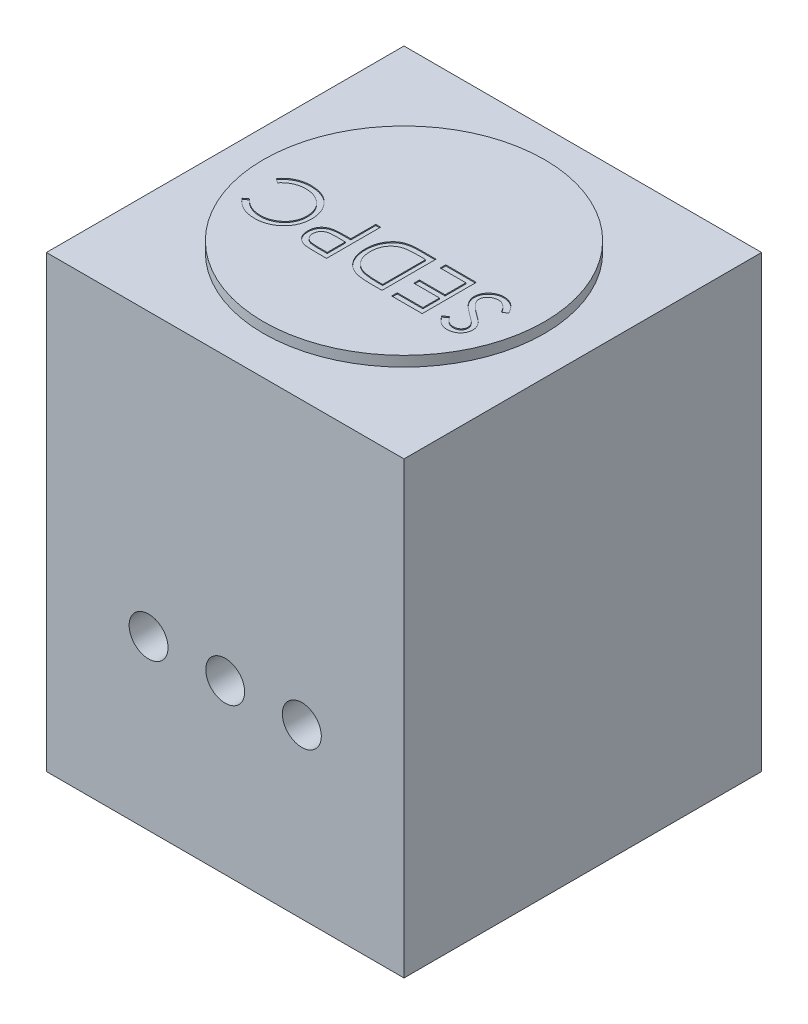
from build123d import *

# Parameters (mm, degrees)
CROQUIS1_W              = 700
CROQUIS1_H              = 700
SALIENTE_EXTRUIR1_DEPTH = 900
CROQUIS2_W              = 700
CROQUIS2_H              = 700
CROQUIS2_R              = 275
CORTAR_EXTRUIR1_DEPTH   = 20
CORTAR_EXTRUIR2_DEPTH   = 2
CROQUIS4_R              = 38.1
CORTAR_EXTRUIR3_DEPTH   = 94


with BuildPart() as part:
    # Croquis1 → Saliente-Extruir1 (new body)
    with BuildSketch(Plane(origin=(0, 0, 0), x_dir=(1, 0, 0), z_dir=(0, 1, 0))):
        Rectangle(CROQUIS1_W, CROQUIS1_H)
    extrude(amount=SALIENTE_EXTRUIR1_DEPTH)

    # Croquis2 → Cortar-Extruir1 (cut)
    with BuildSketch(Plane(origin=(0, 900, 0), x_dir=(1, 0, 0), z_dir=(0, 1, 0))):
        Rectangle(CROQUIS2_W, CROQUIS2_H)
        Circle(CROQUIS2_R, mode=Mode.SUBTRACT)
    extrude(amount=-CORTAR_EXTRUIR1_DEPTH, mode=Mode.SUBTRACT)

    # Croquis3 → Cortar-Extruir2 (cut)
    with BuildSketch(Plane(origin=(0, 900, 0), x_dir=(1, 0, 0), z_dir=(0, 1, 0))):
        with BuildLine():
            Line((225.596474991, -20.416165865), (216.649827021, -25.77991453))
            add(Edge.make_bspline(
                [(216.649827021, -25.77991453), (215.817727942, -24.387015271), (214.223458218, -21.718274043), (211.563976644, -18.112138059), (208.808290997, -15.047139509), (205.935994482, -12.541108757), (202.964619384, -10.568106706), (199.874768236, -9.171039223), (196.676853483, -8.299699015), (194.500502215, -8.193863064), (193.413983004, -8.141025641)],
                knots=[0, 0, 0, 0, 0.004865339, 0.009321801, 0.013419003, 0.01720638, 0.020728614, 0.024078105, 0.027343409, 0.030598786, 0.030598786, 0.030598786, 0.030598786], degree=3))
            add(Edge.make_bspline(
                [(193.413983004, -8.141025641), (192.486258551, -8.16748411), (190.647042645, -8.219938088), (187.934115432, -8.703590884), (185.312497191, -9.494843293), (182.808280262, -10.567480732), (180.487694037, -11.885952935), (178.420448395, -13.440792446), (176.673769299, -15.236952433), (175.229739432, -17.209670794), (174.099328955, -19.317768818), (173.295014972, -21.509329726), (172.7783411, -23.770388295), (172.712834257, -25.3036922), (172.679808324, -26.076722756)],
                knots=[0, 0, 0, 0, 0.002781239, 0.005513813, 0.008236913, 0.010981714, 0.013669176, 0.016226023, 0.018714722, 0.02115721, 0.023537915, 0.025865446, 0.028144287, 0.030461367, 0.030461367, 0.030461367, 0.030461367], degree=3))
            add(Edge.make_bspline(
                [(172.679808324, -26.076722756), (172.723431182, -26.958180652), (172.811772226, -28.743229007), (173.590327709, -31.381364234), (174.779149349, -34.003377867), (175.896508086, -35.625567699), (176.474713506, -36.465010684)],
                knots=[0, 0, 0, 0, 0.002639196, 0.005344661, 0.008190598, 0.011242672, 0.011242672, 0.011242672, 0.011242672], degree=3))
            add(Edge.make_bspline(
                [(176.474713506, -36.465010684), (176.947151926, -37.072504438), (177.941888667, -38.351605232), (179.677170342, -40.222155324), (181.650294936, -42.202722647), (183.912347365, -44.253775405), (186.430342054, -46.41726949), (189.232825966, -48.653080301), (192.287075739, -50.994554054), (194.44132706, -52.54103014), (195.555242352, -53.340678419)],
                knots=[0, 0, 0, 0, 0.00230775, 0.004859054, 0.007647394, 0.010693573, 0.014016389, 0.017605492, 0.021447189, 0.025560594, 0.025560594, 0.025560594, 0.025560594], degree=3))
            add(Edge.make_bspline(
                [(195.555242352, -53.340678419), (196.668581328, -54.13396248), (198.79720067, -55.650661197), (201.77632083, -57.898762949), (204.436738297, -59.967264951), (206.792009221, -61.827353734), (208.78119976, -63.560156947), (210.47702916, -65.072806021), (211.816931859, -66.446074693), (212.562556107, -67.336222832), (212.897323014, -67.735877404)],
                knots=[0, 0, 0, 0, 0.004100985, 0.007840771, 0.011195157, 0.014211457, 0.016842125, 0.019108209, 0.021027301, 0.022590979, 0.022590979, 0.022590979, 0.022590979], degree=3))
            add(Edge.make_bspline(
                [(212.897323014, -67.735877404), (213.365104892, -68.358844442), (214.285060735, -69.583992727), (215.500721687, -71.498375154), (216.525891878, -73.45432894), (217.350962214, -75.458942898), (218.018165335, -77.497151161), (218.482042666, -79.584255794), (218.767966845, -81.706088285), (218.797501996, -83.133685191), (218.812286957, -83.848323985)],
                knots=[0, 0, 0, 0, 0.002336493, 0.004595028, 0.006794991, 0.008952561, 0.0110913, 0.013220666, 0.015358565, 0.017501503, 0.017501503, 0.017501503, 0.017501503], degree=3))
            add(Edge.make_bspline(
                [(218.812286957, -83.848323985), (218.772993837, -84.968129774), (218.69524746, -87.18380629), (218.032308572, -90.418822797), (216.998302387, -93.516973952), (215.502332461, -96.409306115), (213.654529722, -99.091719186), (211.461184354, -101.516629471), (208.881221208, -103.600568575), (206.00906336, -105.372083397), (202.901980533, -106.785357106), (199.636618708, -107.815156875), (196.227650669, -108.418682401), (193.911030361, -108.503812869), (192.7355642, -108.547008547)],
                knots=[0, 0, 0, 0, 0.003356395, 0.00664105, 0.00986584, 0.013127493, 0.016373677, 0.019615218, 0.022899873, 0.026288785, 0.029713713, 0.033113286, 0.036536048, 0.040061726, 0.040061726, 0.040061726, 0.040061726], degree=3))
            add(Edge.make_bspline(
                [(192.7355642, -108.547008547), (191.488035747, -108.505379749), (189.01403765, -108.422824866), (185.373838963, -107.66088521), (181.848142347, -106.477029907), (179.022573206, -105.067081062), (176.810335597, -103.674053849), (175.125040652, -102.402011014), (173.407926203, -100.94074256), (171.677493485, -99.259292037), (169.916645406, -97.391334571), (168.133497014, -95.321044564), (166.311359869, -93.067082562), (165.139522352, -91.457606189), (164.538782683, -90.632512019)],
                knots=[0, 0, 0, 0, 0.003738584, 0.007414059, 0.011108136, 0.014872181, 0.016854294, 0.018944676, 0.021200522, 0.023614505, 0.026179075, 0.02889945, 0.031809805, 0.034871217, 0.034871217, 0.034871217, 0.034871217], degree=3))
            Line((164.538782683, -90.632512019), (173.125020664, -84.123931624))
            add(Edge.make_bspline(
                [(173.125020664, -84.123931624), (173.643443198, -84.791890222), (174.641803787, -86.078222307), (176.158126872, -87.879030984), (177.585131881, -89.526224924), (179.00183693, -90.953174775), (180.299037825, -92.266751989), (181.580422283, -93.371390112), (182.796488553, -94.302157999), (184.325827276, -95.296763085), (186.268091778, -96.259050855), (188.683480995, -97.086388963), (191.209297236, -97.594837302), (192.924018115, -97.659460412), (193.795593581, -97.692307692)],
                knots=[0, 0, 0, 0, 0.002536285, 0.004884292, 0.007062182, 0.00907121, 0.010915174, 0.012598452, 0.014141878, 0.015506149, 0.01806607, 0.020620455, 0.023148398, 0.02576158, 0.02576158, 0.02576158, 0.02576158], degree=3))
            add(Edge.make_bspline(
                [(193.795593581, -97.692307692), (194.889155954, -97.656268146), (196.997987974, -97.586769275), (199.984936989, -96.807764163), (202.688871229, -95.623339381), (205.006568473, -93.915411193), (206.920255143, -91.879231824), (208.321721198, -89.557112654), (209.159633119, -86.992422388), (209.262192079, -85.204232625), (209.314423709, -84.293536325)],
                knots=[0, 0, 0, 0, 0.003273209, 0.006312075, 0.009196601, 0.012080193, 0.014885488, 0.017528769, 0.020156958, 0.022884593, 0.022884593, 0.022884593, 0.022884593], degree=3))
            add(Edge.make_bspline(
                [(209.314423709, -84.293536325), (209.301295475, -83.726806354), (209.274856126, -82.585451636), (208.959634858, -80.902644291), (208.489233207, -79.239647477), (207.822451865, -77.586879899), (206.916288131, -75.897255651), (205.685558693, -74.180405261), (204.145463762, -72.393360445), (202.963481446, -71.232209854), (202.339430386, -70.619157318)],
                knots=[0, 0, 0, 0, 0.001698166, 0.003419988, 0.005117756, 0.006877533, 0.00875567, 0.010855492, 0.013201009, 0.015824491, 0.015824491, 0.015824491, 0.015824491], degree=3))
            add(Edge.make_bspline(
                [(202.339430386, -70.619157318), (202.107765078, -70.412418681), (201.557381333, -69.921255), (200.551180722, -69.117155085), (199.222434204, -68.125261733), (197.605839073, -66.897978592), (195.671587897, -65.474324856), (193.419467985, -63.872503727), (190.87458354, -62.040514847), (189.068706559, -60.7597035), (188.113836102, -60.082465278)],
                knots=[0, 0, 0, 0, 0.000931379, 0.002212744, 0.003862171, 0.005905912, 0.008301673, 0.011066867, 0.014196809, 0.017708755, 0.017708755, 0.017708755, 0.017708755], degree=3))
            add(Edge.make_bspline(
                [(188.113836102, -60.082465278), (186.965215249, -59.246642624), (184.741070163, -57.628187898), (181.576413333, -55.196578893), (178.707042862, -52.818392826), (176.122672292, -50.508971337), (173.798480914, -48.285315901), (171.757897933, -46.122397917), (169.991664731, -44.034401504), (168.064220443, -41.375663935), (166.118073076, -38.080061393), (164.449411663, -34.040506628), (163.387837843, -29.989359604), (163.249968692, -27.270020403), (163.181945076, -25.928318643)],
                knots=[0, 0, 0, 0, 0.004261529, 0.00825186, 0.011970676, 0.015439094, 0.018647746, 0.021617342, 0.024356241, 0.026845483, 0.031463319, 0.035798049, 0.039926996, 0.043948239, 0.043948239, 0.043948239, 0.043948239], degree=3))
            add(Edge.make_bspline(
                [(163.181945076, -25.928318643), (163.201846982, -24.979514187), (163.241264311, -23.100330415), (163.693198702, -20.340695719), (164.357700341, -17.661615366), (165.3480601, -15.096429301), (166.586038555, -12.616548321), (168.093267434, -10.226320582), (169.919857211, -7.965020093), (171.948979314, -5.788731762), (174.202820573, -3.820494135), (176.587844811, -2.067415802), (179.090665436, -0.566391003), (181.739864202, 0.612847406), (184.491801598, 1.556137304), (187.359395441, 2.232262677), (190.348807608, 2.648642474), (192.380851556, 2.69175563), (193.413983004, 2.713675214)],
                knots=[0, 0, 0, 0, 0.002843725, 0.005632227, 0.00836776, 0.011112151, 0.013861697, 0.016673074, 0.019570194, 0.022569759, 0.025589262, 0.028532099, 0.031440832, 0.034325359, 0.037214945, 0.040156331, 0.043151622, 0.04624952, 0.04624952, 0.04624952, 0.04624952], degree=3))
            add(Edge.make_bspline(
                [(193.413983004, 2.713675214), (194.213302142, 2.698040941), (195.801873818, 2.666969293), (198.145256605, 2.398783676), (200.445607623, 2.005486067), (202.6740439, 1.405850193), (204.858310909, 0.661195838), (206.978948453, -0.250518836), (209.041072111, -1.335894482), (211.047229194, -2.596609959), (213.015781715, -4.04991888), (214.938784848, -5.727917191), (216.825865083, -7.62257296), (218.684861126, -9.731249589), (220.471981979, -12.088802008), (222.232168387, -14.657842196), (223.956254987, -17.446669762), (225.039523035, -19.407845848), (225.596474991, -20.416165865)],
                knots=[0, 0, 0, 0, 0.002397167, 0.004764144, 0.007068093, 0.009392435, 0.011678661, 0.013986411, 0.016309786, 0.01866267, 0.021088076, 0.023642901, 0.026311313, 0.029105451, 0.032069441, 0.035180226, 0.038445529, 0.0419009, 0.0419009, 0.0419009, 0.0419009], degree=3))
        make_face()
        Polygon((141.472543367, -105.833333333), (81.771688666, -105.833333333), (81.771688666, -94.978632479), (131.974680119, -94.978632479), (131.974680119, -62.414529915), (81.771688666, -62.414529915), (81.771688666, -51.55982906), (131.974680119, -51.55982906), (131.974680119, -10.854700855), (81.771688666, -10.854700855), (81.771688666, 0), (141.472543367, 0), align=None)
        with BuildLine():
            Line((62.77596217, 0), (62.77596217, -105.833333333))
            Line((62.77596217, -105.833333333), (41.405769863, -105.833333333))
            add(Edge.make_bspline(
                [(41.405769863, -105.833333333), (39.547060879, -105.819987326), (35.956044796, -105.79420291), (30.766863023, -105.62978191), (25.972392541, -105.341857771), (21.575356062, -104.914372381), (17.568689398, -104.401270114), (13.958809683, -103.748732135), (10.739866836, -102.981303285), (8.760199528, -102.326755295), (7.824039093, -102.017227564)],
                knots=[0, 0, 0, 0, 0.005576117, 0.01077303, 0.015573547, 0.019982504, 0.024024317, 0.02768785, 0.030983843, 0.033940774, 0.033940774, 0.033940774, 0.033940774], degree=3))
            add(Edge.make_bspline(
                [(7.824039093, -102.017227564), (6.599445807, -101.550777198), (4.178028948, -100.628454014), (0.732260366, -98.885959299), (-2.522547117, -96.919709404), (-5.560693408, -94.684625027), (-8.388872904, -92.209267924), (-11.042670238, -89.51366571), (-13.446019248, -86.525854877), (-15.681812134, -83.338546129), (-17.638711006, -79.922734262), (-19.364319747, -76.346837544), (-20.837727635, -72.617794268), (-21.987381553, -68.708395318), (-22.937194366, -64.656188932), (-23.574495462, -60.430494967), (-23.997828961, -56.055949527), (-24.040164088, -53.087302542), (-24.061644667, -51.581029647)],
                knots=[0, 0, 0, 0, 0.003928979, 0.007768861, 0.011564773, 0.015325951, 0.019067419, 0.022830448, 0.026658079, 0.030557259, 0.034499086, 0.038453152, 0.04246096, 0.046512104, 0.050667473, 0.054937273, 0.059323131, 0.063840648, 0.063840648, 0.063840648, 0.063840648], degree=3))
            add(Edge.make_bspline(
                [(-24.061644667, -51.581029647), (-24.042613059, -50.272896633), (-24.005109286, -47.695083898), (-23.668763632, -43.89587904), (-23.178951394, -40.20967687), (-22.424096434, -36.652663116), (-21.496548168, -33.200889431), (-20.351717104, -29.870699451), (-18.994801615, -26.659829765), (-17.42116504, -23.593783436), (-15.698097195, -20.680015932), (-13.820531904, -17.964694062), (-11.852755818, -15.417880215), (-9.723000584, -13.097109744), (-7.501780227, -10.930113168), (-5.113547944, -9.013018647), (-2.633082125, -7.256825467), (0.014137629, -5.714866207), (2.849830761, -4.343247616), (5.9480696, -3.184907491), (9.297546455, -2.188069522), (12.920455629, -1.393857248), (16.80471438, -0.753681858), (20.960852053, -0.327357918), (25.381086002, -0.038257084), (28.416373761, -0.012999974), (29.978653143, 0)],
                knots=[0, 0, 0, 0, 0.003923541, 0.007731747, 0.011434574, 0.015072746, 0.018631667, 0.022151539, 0.0256285, 0.029079771, 0.032482977, 0.035776105, 0.038978025, 0.042129719, 0.045218464, 0.048277893, 0.051306907, 0.054328493, 0.057457645, 0.060745445, 0.0642402, 0.067933243, 0.071864737, 0.076043835, 0.080462161, 0.085148259, 0.085148259, 0.085148259, 0.085148259], degree=3))
            Line((29.978653143, 0), (62.77596217, 0))
        make_face()
        with BuildLine():
            Line((53.278098922, -10.854700855), (41.130162224, -10.854700855))
            add(Edge.make_bspline(
                [(41.130162224, -10.854700855), (39.384566251, -10.862202816), (36.027145918, -10.876631836), (31.199392191, -11.003244884), (26.788277107, -11.210132041), (22.793174323, -11.499664156), (19.216339541, -11.882738949), (16.05029758, -12.309849103), (13.305426674, -12.841962495), (11.644465128, -13.324289125), (10.876923709, -13.547175481)],
                knots=[0, 0, 0, 0, 0.005236717, 0.010072124, 0.01448694, 0.018483686, 0.022086851, 0.025276958, 0.02806683, 0.030463622, 0.030463622, 0.030463622, 0.030463622], degree=3))
            add(Edge.make_bspline(
                [(10.876923709, -13.547175481), (9.910845565, -13.887375751), (8.001764035, -14.559650614), (5.25398996, -15.786404602), (2.690004423, -17.237749163), (0.267063101, -18.860555121), (-1.999262557, -20.679880181), (-4.098477364, -22.701510205), (-6.047162539, -24.902040368), (-7.814117763, -27.288885409), (-9.412188594, -29.835562108), (-10.792916528, -32.539233662), (-11.95685454, -35.384728037), (-12.9117883, -38.362145284), (-13.656309186, -41.473257457), (-14.180481184, -44.725871884), (-14.505304429, -48.118704067), (-14.544076559, -50.428394244), (-14.563781419, -51.602230235)],
                knots=[0, 0, 0, 0, 0.003071964, 0.006070555, 0.009013163, 0.01190026, 0.014810615, 0.017719502, 0.02063333, 0.0236184, 0.026618489, 0.029643123, 0.032713989, 0.035831629, 0.039014614, 0.04230132, 0.045708288, 0.049229182, 0.049229182, 0.049229182, 0.049229182], degree=3))
            add(Edge.make_bspline(
                [(-14.563781419, -51.602230235), (-14.548244044, -52.8399733), (-14.517720734, -55.271530506), (-14.134708246, -58.83944945), (-13.573801956, -62.270507493), (-12.766982012, -65.567174861), (-11.724640214, -68.725162499), (-10.477393765, -71.762311693), (-8.963040796, -74.639537233), (-7.248633131, -77.381208114), (-5.323896545, -79.94580347), (-3.197369105, -82.303277685), (-0.891473732, -84.458022184), (1.583162415, -86.413467663), (4.261138919, -88.134839216), (7.097139153, -89.666144484), (10.131111966, -90.96723251), (12.242154648, -91.658994975), (13.314991284, -92.010550214)],
                knots=[0, 0, 0, 0, 0.003711617, 0.007291504, 0.010752464, 0.014135867, 0.017461185, 0.020721185, 0.023973731, 0.027203047, 0.030412819, 0.033580232, 0.036715124, 0.039870595, 0.043028415, 0.046253414, 0.049529917, 0.052915711, 0.052915711, 0.052915711, 0.052915711], degree=3))
            add(Edge.make_bspline(
                [(13.314991284, -92.010550214), (14.202514043, -92.255975533), (16.08963094, -92.777817098), (19.169062352, -93.347060505), (22.634806156, -93.849148928), (26.502249499, -94.274237261), (30.766983857, -94.579258644), (35.432289185, -94.808200776), (40.500181989, -94.962615616), (44.013320513, -94.973159857), (45.836692672, -94.978632479)],
                knots=[0, 0, 0, 0, 0.002761371, 0.005871433, 0.009385363, 0.013267097, 0.017540265, 0.022210221, 0.027279334, 0.03274925, 0.03274925, 0.03274925, 0.03274925], degree=3))
            Line((45.836692672, -94.978632479), (53.278098922, -94.978632479))
            Line((53.278098922, -94.978632479), (53.278098922, -10.854700855))
        make_face(mode=Mode.SUBTRACT)
        with BuildLine():
            Line((-45.771046377, -105.833333333), (-66.526421644, -105.833333333))
            add(Edge.make_bspline(
                [(-66.526421644, -105.833333333), (-67.95398952, -105.83176409), (-70.68927297, -105.82875735), (-74.611609178, -105.737597178), (-78.173951063, -105.615837679), (-81.368617343, -105.447051861), (-84.205437452, -105.247583537), (-86.671574843, -104.967819489), (-88.786413808, -104.675710552), (-90.053585018, -104.378729927), (-90.631489753, -104.243289263)],
                knots=[0, 0, 0, 0, 0.004282571, 0.008205597, 0.011769566, 0.014975344, 0.017802982, 0.020298715, 0.022421528, 0.024201367, 0.024201367, 0.024201367, 0.024201367], degree=3))
            add(Edge.make_bspline(
                [(-90.631489753, -104.243289263), (-91.363051483, -104.043048072), (-92.808936608, -103.647284123), (-94.892440167, -102.854718472), (-96.874413918, -101.914528489), (-98.763148323, -100.844575693), (-100.526287204, -99.594331867), (-102.218879143, -98.235956843), (-103.805428036, -96.714514697), (-105.261977509, -95.032008553), (-106.611533489, -93.243556668), (-107.741208578, -91.303554443), (-108.73875613, -89.279301367), (-109.51615402, -87.121374679), (-110.127218632, -84.858258728), (-110.572257651, -82.484063319), (-110.858293729, -80.003910159), (-110.885434956, -78.308708254), (-110.899251505, -77.445746528)],
                knots=[0, 0, 0, 0, 0.002274399, 0.004495205, 0.006676394, 0.008851083, 0.010997793, 0.013153278, 0.015357426, 0.017581164, 0.019824223, 0.022067581, 0.024305323, 0.026585742, 0.028936045, 0.031331054, 0.033826788, 0.036414649, 0.036414649, 0.036414649, 0.036414649], degree=3))
            add(Edge.make_bspline(
                [(-110.899251505, -77.445746528), (-110.886508424, -76.575561373), (-110.861575725, -74.872985344), (-110.562330907, -72.382189129), (-110.159251303, -70.001894952), (-109.539459483, -67.737380616), (-108.727697463, -65.602094223), (-107.77543777, -63.563404588), (-106.626888161, -61.655995462), (-105.307151643, -59.872942146), (-103.839043908, -58.212570988), (-102.228776493, -56.686914107), (-100.482850267, -55.304901969), (-98.606813885, -54.063436338), (-96.582377979, -52.991305982), (-94.440246193, -52.031025571), (-92.161799173, -51.224543499), (-90.585108869, -50.800301166), (-89.783466248, -50.58460203)],
                knots=[0, 0, 0, 0, 0.002609051, 0.005104784, 0.007516811, 0.009846658, 0.012134456, 0.01436304, 0.016588193, 0.018801599, 0.021009414, 0.023228904, 0.02544728, 0.027681705, 0.029967636, 0.032311811, 0.034719082, 0.037208955, 0.037208955, 0.037208955, 0.037208955], degree=3))
            add(Edge.make_bspline(
                [(-89.783466248, -50.58460203), (-89.120417885, -50.443707447), (-87.667308846, -50.134928775), (-85.274333727, -49.787870196), (-82.486785861, -49.503244239), (-79.314149723, -49.237629018), (-75.749026795, -49.096886158), (-71.799593762, -48.931631083), (-67.452484413, -48.853656243), (-64.420511173, -48.848727264), (-62.8375194, -48.846153846)],
                knots=[0, 0, 0, 0, 0.002033157, 0.004455783, 0.007248874, 0.010439123, 0.014004857, 0.017950958, 0.022297906, 0.027046885, 0.027046885, 0.027046885, 0.027046885], degree=3))
            Line((-62.8375194, -48.846153846), (-55.268909625, -48.846153846))
            Line((-55.268909625, -48.846153846), (-55.268909625, 0))
            Line((-55.268909625, 0), (-45.771046377, 0))
            Line((-45.771046377, 0), (-45.771046377, -105.833333333))
        make_face()
        with BuildLine():
            Line((-55.268909625, -94.978632479), (-55.268909625, -59.700854701))
            Line((-55.268909625, -59.700854701), (-73.798223193, -59.467648237))
            add(Edge.make_bspline(
                [(-73.798223193, -59.467648237), (-74.702959988, -59.467051681), (-76.449535719, -59.465900041), (-78.979330331, -59.588472), (-81.320745603, -59.721816464), (-83.477238523, -59.937466129), (-85.43896628, -60.200491507), (-87.21067848, -60.552157744), (-88.806514252, -60.910834594), (-90.644740321, -61.533202583), (-92.703746309, -62.472123684), (-94.93849697, -63.874519397), (-96.847908146, -65.641185366), (-98.486274663, -67.649019576), (-99.781291482, -69.885003424), (-100.719846316, -72.270733582), (-101.292720698, -74.797151065), (-101.36472615, -76.524071207), (-101.401388257, -77.403345353)],
                knots=[0, 0, 0, 0, 0.002713758, 0.005238854, 0.007596794, 0.009748523, 0.011739347, 0.013531393, 0.015166589, 0.016641516, 0.019345319, 0.021938819, 0.024520072, 0.027112618, 0.029687072, 0.032238199, 0.034779176, 0.037414964, 0.037414964, 0.037414964, 0.037414964], degree=3))
            add(Edge.make_bspline(
                [(-101.401388257, -77.403345353), (-101.363090506, -78.254133451), (-101.286959317, -79.945394892), (-100.724578462, -82.425264252), (-99.771351898, -84.783872385), (-98.485218896, -87.002133961), (-96.886113411, -89.004631634), (-95.014676456, -90.731925095), (-92.900024713, -92.129966907), (-90.948289045, -93.06063002), (-89.20163932, -93.606391585), (-87.691819493, -94.000403802), (-85.978404949, -94.27214565), (-84.077610997, -94.532151487), (-81.991871274, -94.742032776), (-79.707923044, -94.887781063), (-77.23337399, -94.972185155), (-75.51553859, -94.976431339), (-74.62504611, -94.978632479)],
                knots=[0, 0, 0, 0, 0.002551216, 0.005071501, 0.007583211, 0.010157665, 0.012736915, 0.015242623, 0.017765137, 0.020316441, 0.021697574, 0.023250436, 0.024993144, 0.026897071, 0.029006609, 0.031279921, 0.033761839, 0.036433197, 0.036433197, 0.036433197, 0.036433197], degree=3))
            Line((-74.62504611, -94.978632479), (-55.268909625, -94.978632479))
        make_face(mode=Mode.SUBTRACT)
        with BuildLine():
            Line((-230.300960907, -86.413595085), (-221.990330565, -80.053418803))
            add(Edge.make_bspline(
                [(-221.990330565, -80.053418803), (-221.397479766, -80.759951877), (-220.219771083, -82.163492427), (-218.325165472, -84.134535036), (-216.350234051, -85.980518502), (-214.29772469, -87.713303524), (-212.120137575, -89.263245883), (-209.900444905, -90.751056385), (-207.557995407, -92.053685677), (-204.335283827, -93.645010314), (-200.10298894, -95.269350651), (-194.793637765, -96.666423562), (-189.243561821, -97.547385615), (-185.457969593, -97.643446997), (-183.532464646, -97.692307692)],
                knots=[0, 0, 0, 0, 0.002766331, 0.005495367, 0.00819526, 0.01087443, 0.013546041, 0.016209732, 0.018886721, 0.021579446, 0.026989045, 0.032450285, 0.038027289, 0.043800431, 0.043800431, 0.043800431, 0.043800431], degree=3))
            add(Edge.make_bspline(
                [(-183.532464646, -97.692307692), (-182.471625394, -97.680037518), (-180.35979248, -97.655611049), (-177.225469764, -97.335624723), (-174.14373817, -96.880700556), (-171.12605758, -96.222103359), (-168.178419681, -95.364669596), (-165.278380861, -94.359128534), (-162.460095052, -93.107835215), (-159.689647881, -91.725947021), (-157.035487437, -90.164673962), (-154.523694832, -88.462242804), (-152.165598516, -86.635471503), (-149.955201447, -84.688676963), (-147.91477675, -82.599131743), (-146.022648121, -80.390313102), (-144.281230614, -78.052245877), (-142.692320988, -75.596101482), (-141.271141528, -73.034012511), (-140.038748048, -70.376984275), (-138.997013798, -67.635167317), (-138.151893223, -64.814437695), (-137.490467323, -61.924780095), (-137.032619743, -58.95584797), (-136.715581457, -55.912830872), (-136.691370223, -53.85031749), (-136.679166035, -52.810663729)],
                knots=[0, 0, 0, 0, 0.003181219, 0.006332913, 0.009442179, 0.012523567, 0.015590039, 0.018647632, 0.021723763, 0.024833608, 0.027931507, 0.03095391, 0.033930838, 0.036874592, 0.039783016, 0.042685019, 0.045593752, 0.048522274, 0.051454554, 0.054376007, 0.057301534, 0.060245975, 0.06320321, 0.066186773, 0.069254052, 0.072371692, 0.072371692, 0.072371692, 0.072371692], degree=3))
            add(Edge.make_bspline(
                [(-136.679166035, -52.810663729), (-136.717410505, -51.24644202), (-136.792498449, -48.17530018), (-137.457928039, -43.67626528), (-138.477235801, -39.362049332), (-139.979888952, -35.261863493), (-141.869713701, -31.341527746), (-144.227693898, -27.648584193), (-146.968984195, -24.128930123), (-150.121706721, -20.867809518), (-153.581212165, -17.888984226), (-157.292850958, -15.265800717), (-161.247525122, -13.079139367), (-165.401531023, -11.259532571), (-169.786844941, -9.860817452), (-174.395578121, -8.876140324), (-179.217707537, -8.233817262), (-182.512734624, -8.172322407), (-184.189682862, -8.141025641)],
                knots=[0, 0, 0, 0, 0.004690124, 0.009208436, 0.013615151, 0.017967678, 0.022281881, 0.026646113, 0.031086409, 0.035644585, 0.040229846, 0.044764691, 0.049253712, 0.053763511, 0.058349507, 0.063035988, 0.067887635, 0.072915796, 0.072915796, 0.072915796, 0.072915796], degree=3))
            add(Edge.make_bspline(
                [(-184.189682862, -8.141025641), (-186.037311791, -8.192091124), (-189.673887513, -8.29260021), (-195.00692069, -9.144082267), (-200.112192651, -10.524690735), (-204.989978006, -12.456842196), (-209.626525641, -14.968578282), (-214.029091322, -18.013490289), (-218.201391192, -21.620542256), (-220.710284726, -24.374722563), (-221.990330565, -25.77991453)],
                knots=[0, 0, 0, 0, 0.005540213, 0.010904464, 0.016155452, 0.021379666, 0.026606288, 0.031940164, 0.037410819, 0.043109402, 0.043109402, 0.043109402, 0.043109402], degree=3))
            Line((-221.990330565, -25.77991453), (-230.300960907, -19.483340011))
            add(Edge.make_bspline(
                [(-230.300960907, -19.483340011), (-229.63212883, -18.620419973), (-228.297668345, -16.898713237), (-226.137248677, -14.471028562), (-223.859756424, -12.189503332), (-221.459043353, -10.066019605), (-218.93197551, -8.089963443), (-216.279657376, -6.270523131), (-213.5153178, -4.587515621), (-210.635495392, -3.062067019), (-207.640032517, -1.704672582), (-204.554599643, -0.518312933), (-201.373544817, 0.477864751), (-198.121953261, 1.314860241), (-194.766414929, 1.912634898), (-191.345323019, 2.388372043), (-187.826825039, 2.670677419), (-185.455150691, 2.699214039), (-184.253284625, 2.713675214)],
                knots=[0, 0, 0, 0, 0.003274582, 0.006533478, 0.009741569, 0.012940611, 0.016142531, 0.019359227, 0.022584295, 0.025846707, 0.029129514, 0.032444678, 0.035756995, 0.039124953, 0.042509752, 0.045975772, 0.04948471, 0.053089807, 0.053089807, 0.053089807, 0.053089807], degree=3))
            add(Edge.make_bspline(
                [(-184.253284625, 2.713675214), (-183.115011835, 2.705753058), (-180.864218349, 2.690087976), (-177.541089431, 2.436324818), (-174.305928297, 2.090106583), (-171.167981277, 1.568797858), (-168.110124412, 0.953623766), (-165.160078167, 0.128992911), (-162.288813473, -0.794755698), (-159.507866028, -1.880454107), (-156.814870344, -3.105586293), (-154.218512238, -4.490235812), (-151.71998583, -6.022758863), (-149.294726675, -7.669374654), (-146.978561645, -9.48297402), (-144.751419331, -11.438369873), (-142.600811121, -13.528971627), (-141.270253742, -15.03648743), (-140.601274742, -15.794437767)],
                knots=[0, 0, 0, 0, 0.003413887, 0.006750539, 0.00999312, 0.013171795, 0.016290227, 0.019345246, 0.022355506, 0.025335829, 0.028295798, 0.031226468, 0.034157061, 0.037085506, 0.040015946, 0.042975611, 0.045973977, 0.049005884, 0.049005884, 0.049005884, 0.049005884], degree=3))
            add(Edge.make_bspline(
                [(-140.601274742, -15.794437767), (-139.529838268, -17.111067546), (-137.39990064, -19.728431593), (-134.673642638, -23.970012549), (-132.347761215, -28.394638984), (-130.446207831, -33.027939101), (-128.98559299, -37.871714086), (-127.958685808, -42.918171718), (-127.296024174, -48.157223866), (-127.219964416, -51.720333685), (-127.181302787, -53.531483707)],
                knots=[0, 0, 0, 0, 0.005089245, 0.010117048, 0.015095577, 0.020068007, 0.025118243, 0.030249048, 0.035503031, 0.040934521, 0.040934521, 0.040934521, 0.040934521], degree=3))
            add(Edge.make_bspline(
                [(-127.181302787, -53.531483707), (-127.228539213, -55.435057062), (-127.321473932, -59.180218799), (-128.104535228, -64.677853658), (-129.379510295, -69.937397411), (-131.135159458, -74.979087533), (-133.451330112, -79.774077383), (-136.255242002, -84.342618231), (-139.574282573, -88.680979733), (-143.366767845, -92.733695528), (-147.526761181, -96.438953423), (-151.981344208, -99.69883349), (-156.72214676, -102.411713478), (-161.696849174, -104.679456406), (-166.942726836, -106.422514676), (-172.44858079, -107.642718315), (-178.204067106, -108.402212032), (-182.130859489, -108.498224276), (-184.126081099, -108.547008547)],
                knots=[0, 0, 0, 0, 0.00570863, 0.011231373, 0.016620202, 0.021923951, 0.027215144, 0.032563788, 0.037978619, 0.043573687, 0.049190042, 0.054668866, 0.06010168, 0.065547879, 0.071045335, 0.076651598, 0.082444675, 0.088428652, 0.088428652, 0.088428652, 0.088428652], degree=3))
            add(Edge.make_bspline(
                [(-184.126081099, -108.547008547), (-185.342088523, -108.532427816), (-187.749052759, -108.503566728), (-191.309691987, -108.222192668), (-194.776171888, -107.752995354), (-198.158135753, -107.113557359), (-201.461161909, -106.318219393), (-204.67040632, -105.3223512), (-207.776673592, -104.118280731), (-210.80090936, -102.77818011), (-213.704337847, -101.243403098), (-216.485514803, -99.575169516), (-219.121857621, -97.741354801), (-221.630503789, -95.768704532), (-223.999855079, -93.642043386), (-226.265470568, -91.397117767), (-228.360079168, -88.974376644), (-229.652816028, -87.268751491), (-230.300960907, -86.413595085)],
                knots=[0, 0, 0, 0, 0.003647487, 0.007219833, 0.010706863, 0.014137233, 0.017541231, 0.020894009, 0.024209174, 0.027530637, 0.0308118, 0.034055005, 0.037254257, 0.0404395, 0.043622696, 0.046800805, 0.050001813, 0.053220464, 0.053220464, 0.053220464, 0.053220464], degree=3))
        make_face()
    extrude(amount=-CORTAR_EXTRUIR2_DEPTH, mode=Mode.SUBTRACT)

    # Croquis4 → Cortar-Extruir3 (cut)
    with BuildSketch(Plane.XY.offset(350)):
        with Locations((0, 328.970025761)):
            Circle(CROQUIS4_R)
        with Locations((-150, 328.970025761)):
            Circle(CROQUIS4_R)
        with Locations((150, 328.970025761)):
            Circle(CROQUIS4_R)
    extrude(amount=-CORTAR_EXTRUIR3_DEPTH, mode=Mode.SUBTRACT)


solid = part.part
